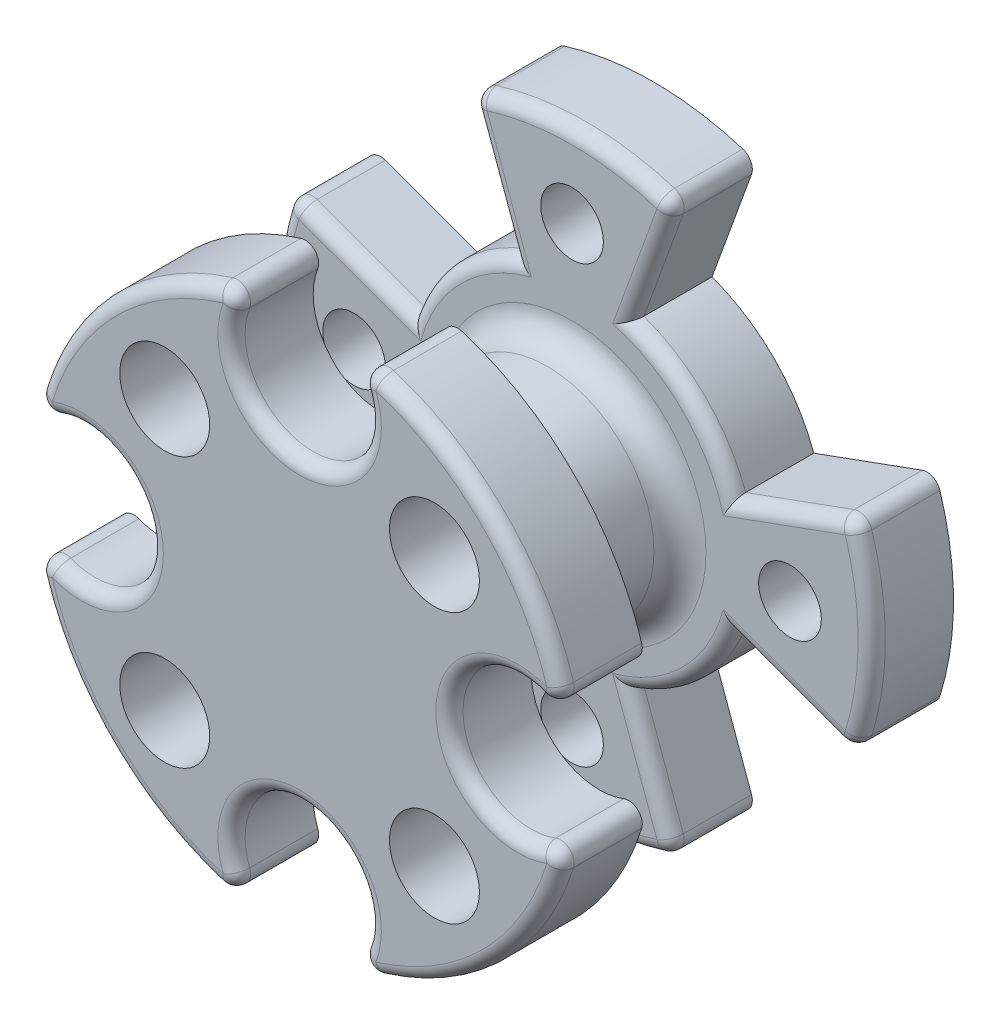
from build123d import *

# Parameters (mm, degrees)
SKETCH1_R           = 11
BOSS_EXTRUDE1_DEPTH = 3
SKETCH2_R           = 4.5
CUT_EXTRUDE1_DEPTH  = 1.5
CUT_EXTRUDE2_REACH  = 5
SKETCH3_R           = 1.15
CUT_EXTRUDE4_DEPTH  = 10
SKETCH4_R           = 4
BOSS_EXTRUDE2_DEPTH = 7
BOSS_EXTRUDE2_TAPER = 5
SKETCH6_R           = 10
BOSS_EXTRUDE3_DEPTH = 3
CUT_EXTRUDE3_REACH  = 15
SKETCH7_R           = 1.65
CUT_EXTRUDE5_REACH  = 15
SKETCH9_R           = 2.5
FILLET1_R           = 1
FILLET2_R           = 0.5


with BuildPart() as part:
    # Sketch1 → Boss-Extrude1 (new body)
    with BuildSketch(Plane.XY):
        Circle(SKETCH1_R)
    extrude(amount=BOSS_EXTRUDE1_DEPTH)

    # Sketch2 → Cut-Extrude1 (cut)
    with BuildSketch(Plane(origin=(0, 0, 0), x_dir=(-1, 0, 0), z_dir=(0, 0, -1))):
        Circle(SKETCH2_R)
    extrude(amount=-CUT_EXTRUDE1_DEPTH, mode=Mode.SUBTRACT)

    # Sketch3 → Cut-Extrude2 (cut, up to next)
    with BuildSketch(Plane.XY.offset(3), mode=Mode.PRIVATE) as cut_extrude2_sk1:
        with Locations((0, 8)):
            Circle(SKETCH3_R)
    cut_extrude2_tool1 = extrude(cut_extrude2_sk1.sketch, amount=-CUT_EXTRUDE2_REACH, mode=Mode.PRIVATE) & part.part
    add(cut_extrude2_tool1.solids().sort_by_distance((0, 8, 3))[0], mode=Mode.SUBTRACT)
    # Sketch3 → Cut-Extrude2 (cut, up to next)
    with BuildSketch(Plane.XY.offset(3), mode=Mode.PRIVATE) as cut_extrude2_sk2:
        with Locations((8, 0)):
            Circle(SKETCH3_R)
    cut_extrude2_tool2 = extrude(cut_extrude2_sk2.sketch, amount=-CUT_EXTRUDE2_REACH, mode=Mode.PRIVATE) & part.part
    add(cut_extrude2_tool2.solids().sort_by_distance((8, 0, 3))[0], mode=Mode.SUBTRACT)
    # Sketch3 → Cut-Extrude2 (cut, up to next)
    with BuildSketch(Plane.XY.offset(3), mode=Mode.PRIVATE) as cut_extrude2_sk3:
        with Locations((0, -8)):
            Circle(SKETCH3_R)
    cut_extrude2_tool3 = extrude(cut_extrude2_sk3.sketch, amount=-CUT_EXTRUDE2_REACH, mode=Mode.PRIVATE) & part.part
    add(cut_extrude2_tool3.solids().sort_by_distance((0, -8, 3))[0], mode=Mode.SUBTRACT)
    # Sketch3 → Cut-Extrude2 (cut, up to next)
    with BuildSketch(Plane.XY.offset(3), mode=Mode.PRIVATE) as cut_extrude2_sk4:
        with Locations((-8, 0)):
            Circle(SKETCH3_R)
    cut_extrude2_tool4 = extrude(cut_extrude2_sk4.sketch, amount=-CUT_EXTRUDE2_REACH, mode=Mode.PRIVATE) & part.part
    add(cut_extrude2_tool4.solids().sort_by_distance((-8, 0, 3))[0], mode=Mode.SUBTRACT)

    # Sketch8 → Cut-Extrude4 (cut)
    with BuildSketch(Plane.XY.offset(3)):
        with BuildLine():
            Line((3.762221577, 10.336618829), (2.137625896, 5.87307888))
            ThreePointArc((2.137625896, 5.87307888), (4.419417382, 4.419417382), (5.87307888, 2.137625896))
            Line((5.87307888, 2.137625896), (10.336618829, 3.762221577))
            ThreePointArc((10.336618829, 3.762221577), (7.778174593, 7.778174593), (3.762221577, 10.336618829))
        make_face()
        with BuildLine():
            ThreePointArc((5.87307888, -2.137625896), (4.419417382, -4.419417382), (2.137625896, -5.87307888))
            Line((2.137625896, -5.87307888), (3.762221577, -10.336618829))
            ThreePointArc((3.762221577, -10.336618829), (7.778174593, -7.778174593), (10.336618829, -3.762221577))
            Line((10.336618829, -3.762221577), (5.87307888, -2.137625896))
        make_face()
        with BuildLine():
            ThreePointArc((-2.137625896, -5.87307888), (-4.419417382, -4.419417382), (-5.87307888, -2.137625896))
            Line((-5.87307888, -2.137625896), (-10.336618829, -3.762221577))
            ThreePointArc((-10.336618829, -3.762221577), (-7.778174593, -7.778174593), (-3.762221577, -10.336618829))
            Line((-3.762221577, -10.336618829), (-2.137625896, -5.87307888))
        make_face()
        with BuildLine():
            ThreePointArc((-5.87307888, 2.137625896), (-4.419417382, 4.419417382), (-2.137625896, 5.87307888))
            Line((-2.137625896, 5.87307888), (-3.762221577, 10.336618829))
            ThreePointArc((-3.762221577, 10.336618829), (-7.778174593, 7.778174593), (-10.336618829, 3.762221577))
            Line((-10.336618829, 3.762221577), (-5.87307888, 2.137625896))
        make_face()
    extrude(amount=-CUT_EXTRUDE4_DEPTH, mode=Mode.SUBTRACT)

    # Sketch4 → Boss-Extrude2 (add)
    with BuildSketch(Plane.XY.offset(3)):
        Circle(SKETCH4_R)
    extrude(amount=BOSS_EXTRUDE2_DEPTH, taper=BOSS_EXTRUDE2_TAPER)

    # Sketch6 → Boss-Extrude3 (add)
    with BuildSketch(Plane.XY.offset(10)):
        Circle(SKETCH6_R)
    extrude(amount=BOSS_EXTRUDE3_DEPTH)

    # Sketch7 → Cut-Extrude3 (cut, up to next)
    with BuildSketch(Plane.XY.offset(13), mode=Mode.PRIVATE) as cut_extrude3_sk1:
        with Locations((-4.949747468, 4.949747468)):
            Circle(SKETCH7_R)
    cut_extrude3_tool1 = extrude(cut_extrude3_sk1.sketch, amount=-CUT_EXTRUDE3_REACH, mode=Mode.PRIVATE) & part.part
    add(cut_extrude3_tool1.solids().sort_by_distance((-4.949747, 4.949747, 13))[0], mode=Mode.SUBTRACT)
    # Sketch7 → Cut-Extrude3 (cut, up to next)
    with BuildSketch(Plane.XY.offset(13), mode=Mode.PRIVATE) as cut_extrude3_sk2:
        with Locations((4.949747468, 4.949747468)):
            Circle(SKETCH7_R)
    cut_extrude3_tool2 = extrude(cut_extrude3_sk2.sketch, amount=-CUT_EXTRUDE3_REACH, mode=Mode.PRIVATE) & part.part
    add(cut_extrude3_tool2.solids().sort_by_distance((4.949747, 4.949747, 13))[0], mode=Mode.SUBTRACT)
    # Sketch7 → Cut-Extrude3 (cut, up to next)
    with BuildSketch(Plane.XY.offset(13), mode=Mode.PRIVATE) as cut_extrude3_sk3:
        with Locations((4.949747468, -4.949747468)):
            Circle(SKETCH7_R)
    cut_extrude3_tool3 = extrude(cut_extrude3_sk3.sketch, amount=-CUT_EXTRUDE3_REACH, mode=Mode.PRIVATE) & part.part
    add(cut_extrude3_tool3.solids().sort_by_distance((4.949747, -4.949747, 13))[0], mode=Mode.SUBTRACT)
    # Sketch7 → Cut-Extrude3 (cut, up to next)
    with BuildSketch(Plane.XY.offset(13), mode=Mode.PRIVATE) as cut_extrude3_sk4:
        with Locations((-4.949747468, -4.949747468)):
            Circle(SKETCH7_R)
    cut_extrude3_tool4 = extrude(cut_extrude3_sk4.sketch, amount=-CUT_EXTRUDE3_REACH, mode=Mode.PRIVATE) & part.part
    add(cut_extrude3_tool4.solids().sort_by_distance((-4.949747, -4.949747, 13))[0], mode=Mode.SUBTRACT)

    # Sketch9 → Cut-Extrude5 (cut, up to next)
    with BuildSketch(Plane.XY.offset(13), mode=Mode.PRIVATE) as cut_extrude5_sk1:
        with Locations((8, 0)):
            Circle(SKETCH9_R)
    cut_extrude5_tool1 = extrude(cut_extrude5_sk1.sketch, amount=-CUT_EXTRUDE5_REACH, mode=Mode.PRIVATE) & part.part
    add(cut_extrude5_tool1.solids().sort_by_distance((8, 0, 13))[0], mode=Mode.SUBTRACT)
    # Sketch9 → Cut-Extrude5 (cut, up to next)
    with BuildSketch(Plane.XY.offset(13), mode=Mode.PRIVATE) as cut_extrude5_sk2:
        with Locations((0, 8)):
            Circle(SKETCH9_R)
    cut_extrude5_tool2 = extrude(cut_extrude5_sk2.sketch, amount=-CUT_EXTRUDE5_REACH, mode=Mode.PRIVATE) & part.part
    add(cut_extrude5_tool2.solids().sort_by_distance((0, 8, 13))[0], mode=Mode.SUBTRACT)
    # Sketch9 → Cut-Extrude5 (cut, up to next)
    with BuildSketch(Plane.XY.offset(13), mode=Mode.PRIVATE) as cut_extrude5_sk3:
        with Locations((-8, 0)):
            Circle(SKETCH9_R)
    cut_extrude5_tool3 = extrude(cut_extrude5_sk3.sketch, amount=-CUT_EXTRUDE5_REACH, mode=Mode.PRIVATE) & part.part
    add(cut_extrude5_tool3.solids().sort_by_distance((-8, 0, 13))[0], mode=Mode.SUBTRACT)
    # Sketch9 → Cut-Extrude5 (cut, up to next)
    with BuildSketch(Plane.XY.offset(13), mode=Mode.PRIVATE) as cut_extrude5_sk4:
        with Locations((0, -8)):
            Circle(SKETCH9_R)
    cut_extrude5_tool4 = extrude(cut_extrude5_sk4.sketch, amount=-CUT_EXTRUDE5_REACH, mode=Mode.PRIVATE) & part.part
    add(cut_extrude5_tool4.solids().sort_by_distance((0, -8, 13))[0], mode=Mode.SUBTRACT)

    # Fillet1
    fillet1_edges = [part.edges().sort_by_distance(p)[0] for p in [
        (-4, 0, 3),
    ]]
    fillet(fillet1_edges, radius=FILLET1_R)

    # Fillet2
    fillet2_edges = [part.edges().sort_by_distance(p)[0] for p in [
        (7.071067812, 7.071067812, 13),
        (-7.071067812, 7.071067812, 13),
        (-7.071067812, -7.071067812, 13),
        (7.071067812, -7.071067812, 13),
        (9.859375, -1.6711447, 11.5),
        (9.859375, 1.6711447, 11.5),
        (5.5, 0, 13),
        (1.6711447, 9.859375, 11.5),
        (-1.6711447, 9.859375, 11.5),
        (0, 5.5, 13),
        (-9.859375, 1.6711447, 11.5),
        (-9.859375, -1.6711447, 11.5),
        (-5.5, 0, 13),
        (-1.6711447, -9.859375, 11.5),
        (1.6711447, -9.859375, 11.5),
        (0, -5.5, 13),
        (0, 11, 3),
        (-11, 0, 3),
        (0, -11, 3),
        (11, 0, 3),
        (-4.419417382, 4.419417382, 3),
        (-8.104848854, 2.949923736, 3),
        (-10.336618829, 3.762221577, 1.5),
        (-3.762221577, 10.336618829, 1.5),
        (-2.949923736, 8.104848854, 3),
        (-4.419417382, -4.419417382, 3),
        (-2.949923736, -8.104848854, 3),
        (-3.762221577, -10.336618829, 1.5),
        (-10.336618829, -3.762221577, 1.5),
        (-8.104848854, -2.949923736, 3),
        (4.419417382, -4.419417382, 3),
        (8.104848854, -2.949923736, 3),
        (10.336618829, -3.762221577, 1.5),
        (3.762221577, -10.336618829, 1.5),
        (2.949923736, -8.104848854, 3),
        (4.419417382, 4.419417382, 3),
        (2.949923736, 8.104848854, 3),
        (3.762221577, 10.336618829, 1.5),
        (10.336618829, 3.762221577, 1.5),
        (8.104848854, 2.949923736, 3),
    ]]
    fillet(fillet2_edges, radius=FILLET2_R)


solid = part.part
